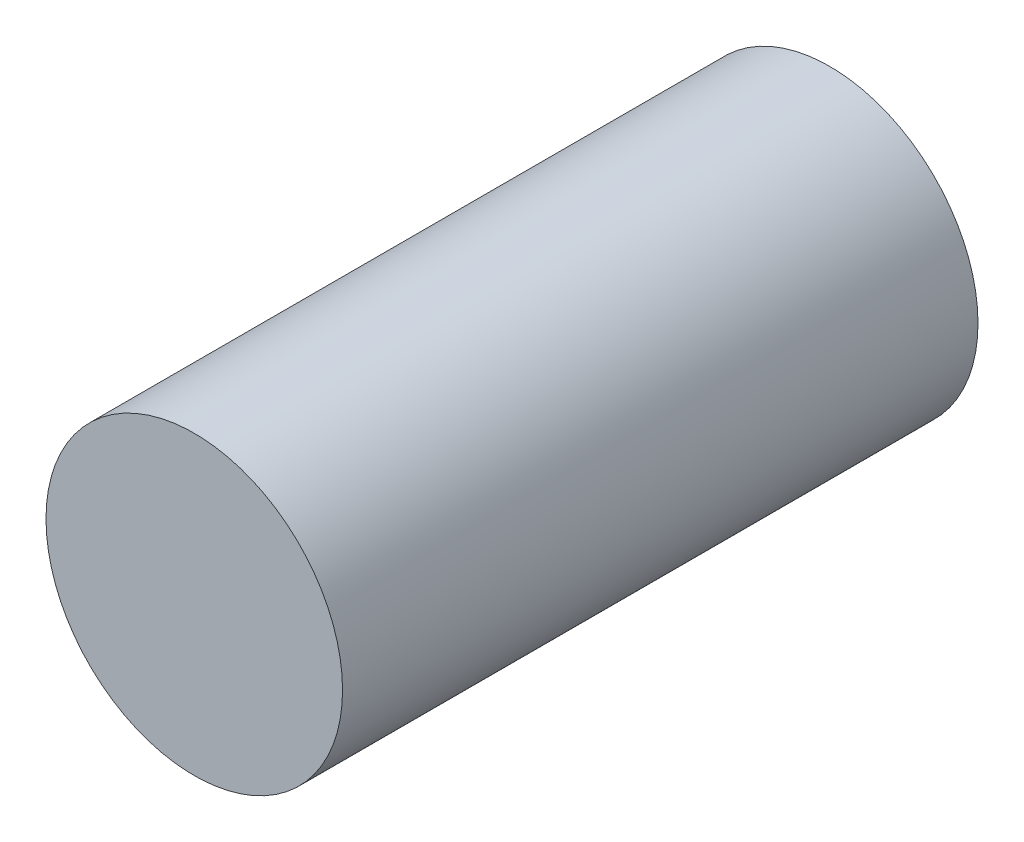
from build123d import *

# Parameters (mm, degrees)
SKETCH_1_R      = 7
EXTRUDE_1_DEPTH = 30


with BuildPart() as part:
    # 草图1 → 凸台-拉伸1 (new body)
    with BuildSketch(Plane.XY):
        with Locations((-11.585368153, 17.564913006)):
            Circle(SKETCH_1_R)
    extrude(amount=EXTRUDE_1_DEPTH)


solid = part.part
